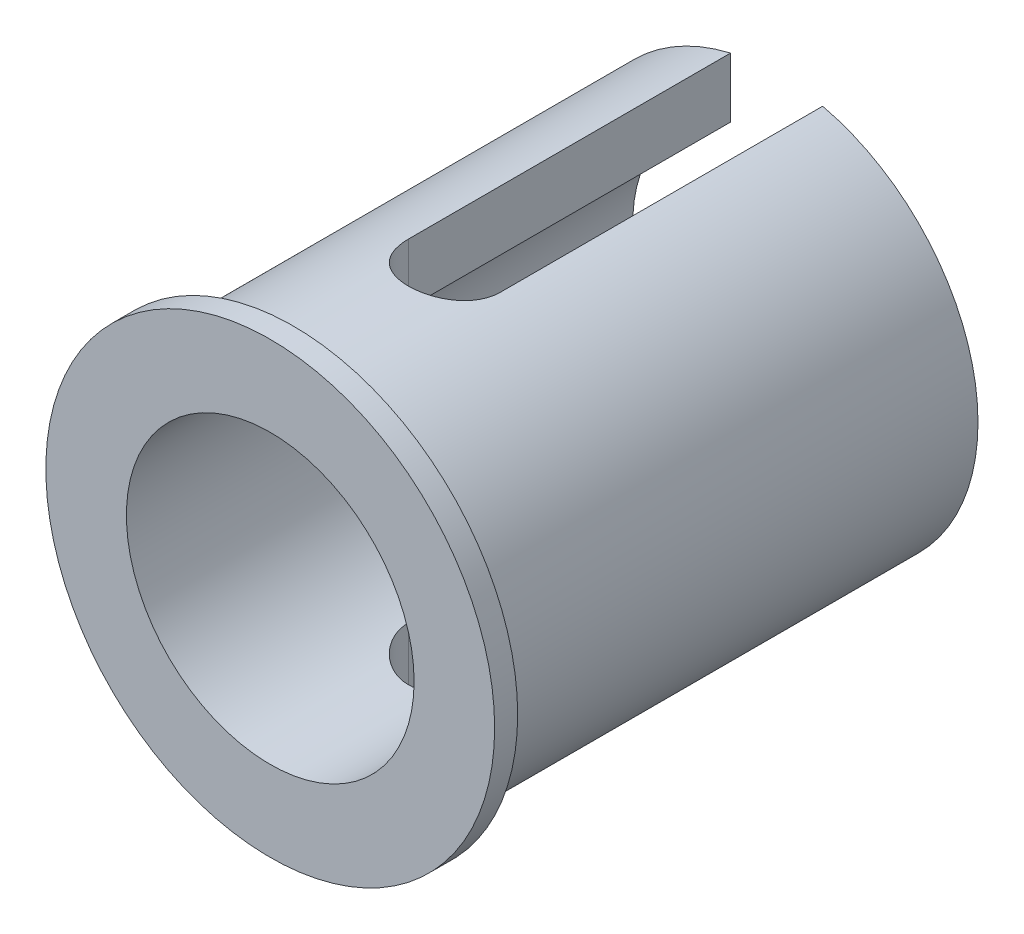
from build123d import *

# Parameters (mm, degrees)
SKETCH_1_R               = 17.5
SKETCH_1_R_2             = 12.5
EXTRUDE_1_DEPTH          = 2
EXTRUDE_1_DEPTH_BACK     = 42
SKETCH_2_R               = 19.5
SKETCH_2_R_2             = 17.5
EXTRUDE_2_DEPTH          = 2
CUT_EXTRUDE_1_DEPTH      = 20.5
CUT_EXTRUDE_1_DEPTH_BACK = 20.5


with BuildPart() as part:
    # Эскиз1 → Бобышка-Вытянуть1 (new body, two sides)
    with BuildSketch(Plane.XY) as extrude_1_sk:
        Circle(SKETCH_1_R)
        Circle(SKETCH_1_R_2, mode=Mode.SUBTRACT)
    extrude(amount=EXTRUDE_1_DEPTH)
    extrude(extrude_1_sk.sketch, amount=-EXTRUDE_1_DEPTH_BACK)

    # Эскиз2 → Бобышка-Вытянуть2 (add)
    with BuildSketch(Plane.XY.offset(2)):
        Circle(SKETCH_2_R)
        Circle(SKETCH_2_R_2, mode=Mode.SUBTRACT)
    extrude(amount=-EXTRUDE_2_DEPTH)

    # Эскиз3 → Вырез-Вытянуть1 (cut, two sides)
    with BuildSketch(Plane(origin=(0, 0, 0), x_dir=(1, 0, 0), z_dir=(0, 1, 0))) as cut_extrude_1_sk:
        with BuildLine():
            Line((4, 42), (4, 14))
            ThreePointArc((4, 14), (0, 10), (-4, 14))
            Line((-4, 14), (-4, 42))
            ThreePointArc((-4, 42), (0, 46), (4, 42))
        make_face()
    extrude(amount=CUT_EXTRUDE_1_DEPTH, mode=Mode.SUBTRACT)
    extrude(cut_extrude_1_sk.sketch, amount=-CUT_EXTRUDE_1_DEPTH_BACK, mode=Mode.SUBTRACT)


solid = part.part
